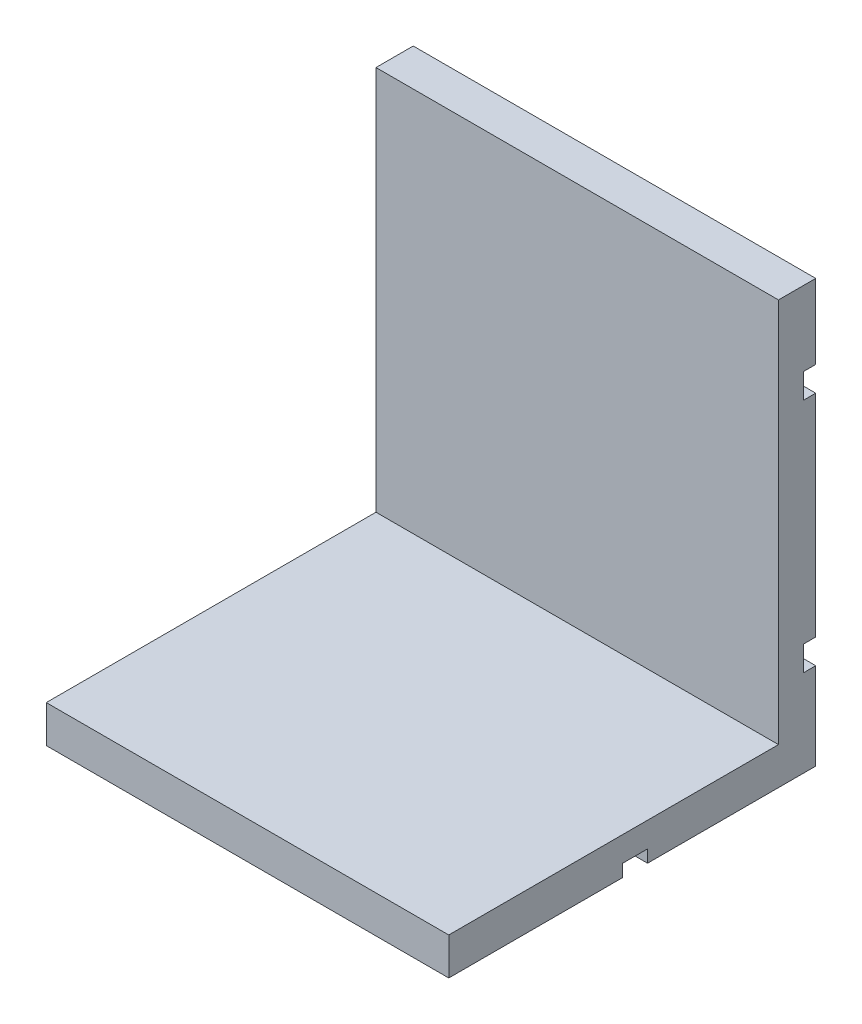
from build123d import *

# Parameters (mm, degrees)
BOSS_EXTRUDE1_DEPTH = 16.2


with BuildPart() as part:
    # Sketch1 → Boss-Extrude1 (new body)
    with BuildSketch(Plane(origin=(0, 0, 0), x_dir=(0, 0, -1), z_dir=(1, 0, 0))):
        Polygon((-6.77, 0), (0, 0), (0, 3.5), (-0.5, 3.5), (-0.5, 4.5), (0, 4.5), (0, 13), (-0.5, 13), (-0.5, 14), (0, 14), (0, 17), (-1.5, 17), (-1.5, 1.5), (-14.77, 1.5), (-14.77, 0), (-7.77, 0), (-7.77, 0.5), (-6.77, 0.5), align=None)
    extrude(amount=BOSS_EXTRUDE1_DEPTH)


solid = part.part
